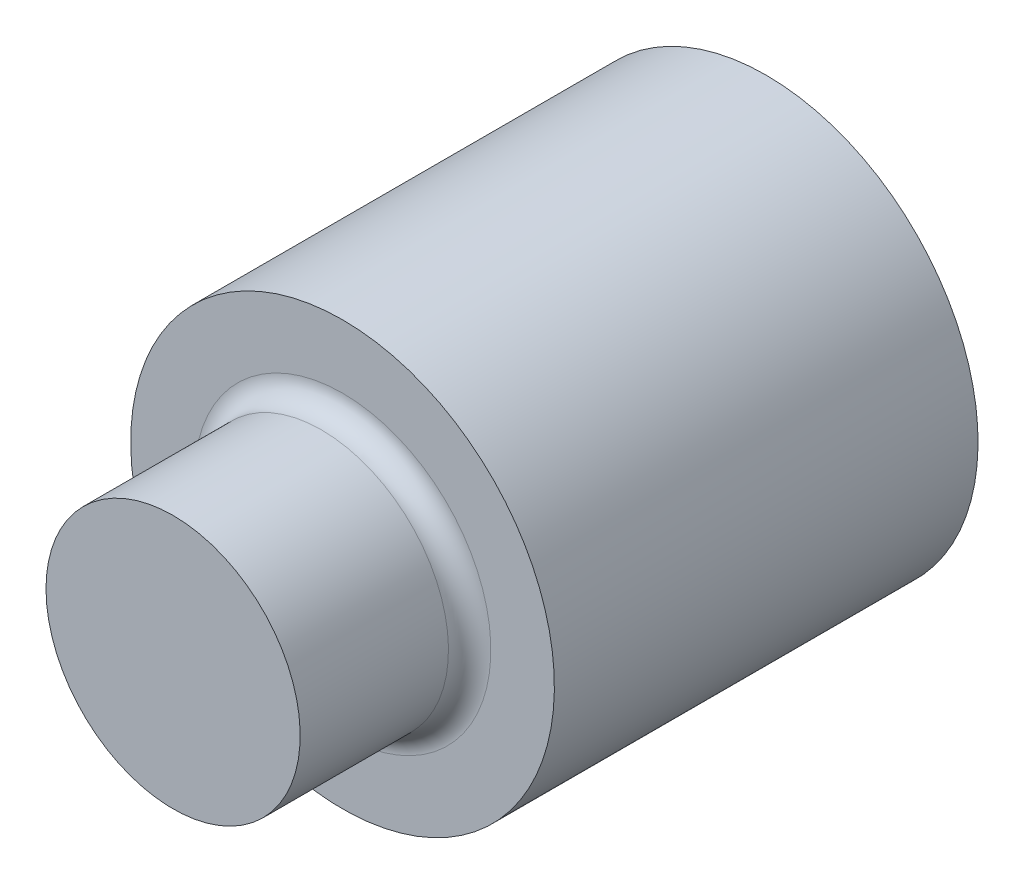
from build123d import *

# Parameters (mm, degrees)
SKETCH3_W               = 57.459303788
SKETCH3_H               = 5.287178435
CUT_EXTRUDE1_DEPTH      = 3.5
CUT_EXTRUDE1_DEPTH_BACK = 3.5


with BuildPart() as part:
    # Sketch2 → Revolve1 (revolve)
    with BuildSketch(Plane(origin=(0, 0, 0), x_dir=(0, 0, -1), z_dir=(1, 0, 0))):
        with BuildLine():
            Line((-29, 1.5), (28.75, 1.5))
            ThreePointArc((28.75, 1.5), (28.926776695, 1.573223305), (29, 1.75))
            Line((29, 1.75), (29, 2.5))
            Line((29, 2.5), (34, 2.5))
            Line((34, 2.5), (34, 0))
            Line((34, 0), (-29, 0))
            Line((-29, 0), (-29, 1.5))
        make_face()
    revolve(axis=Axis((0, 0, -34), (0, 0, 1)))

    # Sketch3 → Cut-Extrude1 (cut, two sides)
    with BuildSketch(Plane(origin=(0, 0, 0), x_dir=(0, 0, -1), z_dir=(1, 0, 0))) as cut_extrude1_sk:
        with Locations((-1.729651894, 0.054546596)):
            Rectangle(SKETCH3_W, SKETCH3_H)
    extrude(amount=CUT_EXTRUDE1_DEPTH, mode=Mode.SUBTRACT)
    extrude(cut_extrude1_sk.sketch, amount=-CUT_EXTRUDE1_DEPTH_BACK, mode=Mode.SUBTRACT)


solid = part.part
